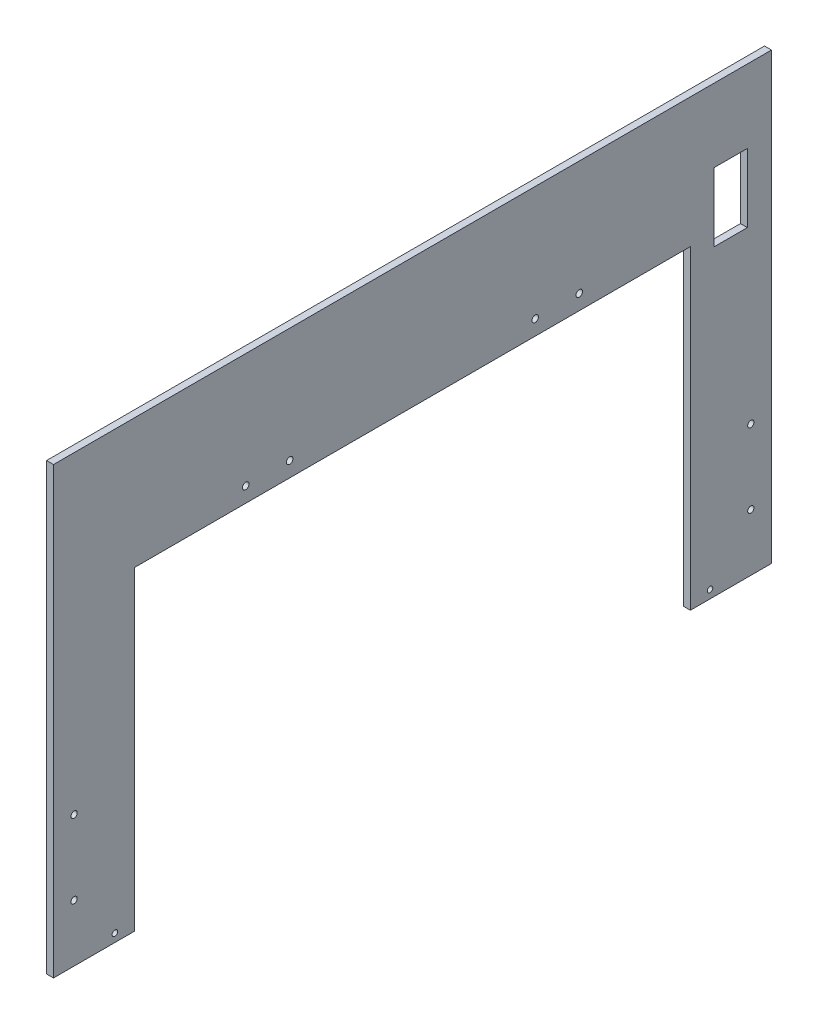
from build123d import *

# Parameters (mm, degrees)
SKETCH1_W                 = 492.125
SKETCH1_H                 = 304.8
BOSS_EXTRUDE1_DEPTH       = 4.7625
CUT_EXTRUDE1_REACH        = 6.763
BOSS_EXTRUDE2_REACH       = 494.125
SKETCH3_W                 = 4.7625
SKETCH3_H                 = 304.8
F_8_CLEARANCE_HOLE1_D     = 4.3053
F_8_CLEARANCE_HOLE1_DEPTH = 74.422
F_8_CLEARANCE_HOLE1_TIP   = 1.293442612
SKETCH9_W                 = 381
SKETCH9_H                 = 215.9
CUT_EXTRUDE2_DEPTH        = 5.7625
F_8_CLEARANCE_HOLE2_D     = 4.4958
F_8_CLEARANCE_HOLE2_DEPTH = 74.422
F_8_CLEARANCE_HOLE2_TIP   = 1.350674586
F_6_CLEARANCE_HOLE1_D     = 3.7973
F_6_CLEARANCE_HOLE1_DEPTH = 74.422
F_6_CLEARANCE_HOLE1_TIP   = 1.140824014
SKETCH14_W                = 22.86
SKETCH14_H                = 46.99
CUT_EXTRUDE3_DEPTH        = 46.736


with BuildPart() as part:
    # Sketch1 → Boss-Extrude1 (new body)
    with BuildSketch(Plane(origin=(0, 0, 0), x_dir=(0, 0, -1), z_dir=(1, 0, 0))):
        Rectangle(SKETCH1_W, SKETCH1_H)
    extrude(amount=BOSS_EXTRUDE1_DEPTH)

    # Sketch2 → Cut-Extrude1 (cut, up to next)
    with BuildSketch(Plane(origin=(4.7625, 0, 0), x_dir=(0, 0, -1), z_dir=(1, 0, 0)), mode=Mode.PRIVATE) as cut_extrude1_sk1:
        Polygon((-24.852813742, -60), (24.852813742, -60), (42.426406871, -42.426406871), (60, -24.852813742), (60, 24.852813742), (24.852813742, 60), (-24.852813742, 60), (-60, 24.852813742), (-60, -24.852813742), align=None)
    cut_extrude1_tool1 = extrude(cut_extrude1_sk1.sketch, amount=-CUT_EXTRUDE1_REACH, mode=Mode.PRIVATE) & part.part
    add(cut_extrude1_tool1.solids().sort_by_distance((4.7625, 0, 0))[0], mode=Mode.SUBTRACT)

    # Sketch3 → Boss-Extrude2 (add, up to next)
    with BuildSketch(Plane.XY.offset(246.0625), mode=Mode.PRIVATE) as boss_extrude2_sk1:
        with Locations((2.38125, 0)):
            Rectangle(SKETCH3_W, SKETCH3_H)
    boss_extrude2_tool1 = extrude(boss_extrude2_sk1.sketch, amount=-BOSS_EXTRUDE2_REACH, mode=Mode.PRIVATE) - part.part
    add(boss_extrude2_tool1.solids().sort_by_distance((2.38125, 0, 246.0625))[0])

    # #8 Clearance Hole1
    with Locations(Plane(origin=(4.7625, 0, 0), x_dir=(0, 0, -1), z_dir=(1, 0, 0))):
        with Locations((-231.93375, -113.284), (-231.93375, -62.484), (231.93375, -62.484), (231.93375, -113.284)):
            Hole(F_8_CLEARANCE_HOLE1_D / 2, depth=F_8_CLEARANCE_HOLE1_DEPTH)
            with Locations((0, 0, -(F_8_CLEARANCE_HOLE1_DEPTH + F_8_CLEARANCE_HOLE1_TIP / 2))):  # 118° drill point
                Cone(0, F_8_CLEARANCE_HOLE1_D / 2, F_8_CLEARANCE_HOLE1_TIP, mode=Mode.SUBTRACT)

    # Sketch9 → Cut-Extrude2 (cut, through all)
    with BuildSketch(Plane(origin=(4.7625, 0, 0), x_dir=(0, 0, -1), z_dir=(1, 0, 0))):
        with Locations((0, -44.45)):
            Rectangle(SKETCH9_W, SKETCH9_H)
    extrude(amount=-CUT_EXTRUDE2_DEPTH, mode=Mode.SUBTRACT)

    # #8 Clearance Hole2
    with Locations(Plane(origin=(4.7625, 0, 0), x_dir=(0, 0, -1), z_dir=(1, 0, 0))):
        with Locations((-114.3, 73.81875), (-84.1375, 73.81875), (84.1375, 73.81875), (114.3, 73.81875)):
            Hole(F_8_CLEARANCE_HOLE2_D / 2, depth=F_8_CLEARANCE_HOLE2_DEPTH)
            with Locations((0, 0, -(F_8_CLEARANCE_HOLE2_DEPTH + F_8_CLEARANCE_HOLE2_TIP / 2))):  # 118° drill point
                Cone(0, F_8_CLEARANCE_HOLE2_D / 2, F_8_CLEARANCE_HOLE2_TIP, mode=Mode.SUBTRACT)

    # #6 Clearance Hole1
    with Locations(Plane(origin=(4.7625, 0, 0), x_dir=(0, 0, -1), z_dir=(1, 0, 0))):
        with Locations((-203.97089, -146.812), (203.97089, -146.812)):
            Hole(F_6_CLEARANCE_HOLE1_D / 2, depth=F_6_CLEARANCE_HOLE1_DEPTH)
            with Locations((0, 0, -(F_6_CLEARANCE_HOLE1_DEPTH + F_6_CLEARANCE_HOLE1_TIP / 2))):  # 118° drill point
                Cone(0, F_6_CLEARANCE_HOLE1_D / 2, F_6_CLEARANCE_HOLE1_TIP, mode=Mode.SUBTRACT)

    # Sketch14 → Cut-Extrude3 (cut)
    with BuildSketch(Plane(origin=(4.7625, 0, 0), x_dir=(0, 0, -1), z_dir=(1, 0, 0))):
        with Locations((218.1225, 78.74)):
            Rectangle(SKETCH14_W, SKETCH14_H)
    extrude(amount=-CUT_EXTRUDE3_DEPTH, mode=Mode.SUBTRACT)


solid = part.part
